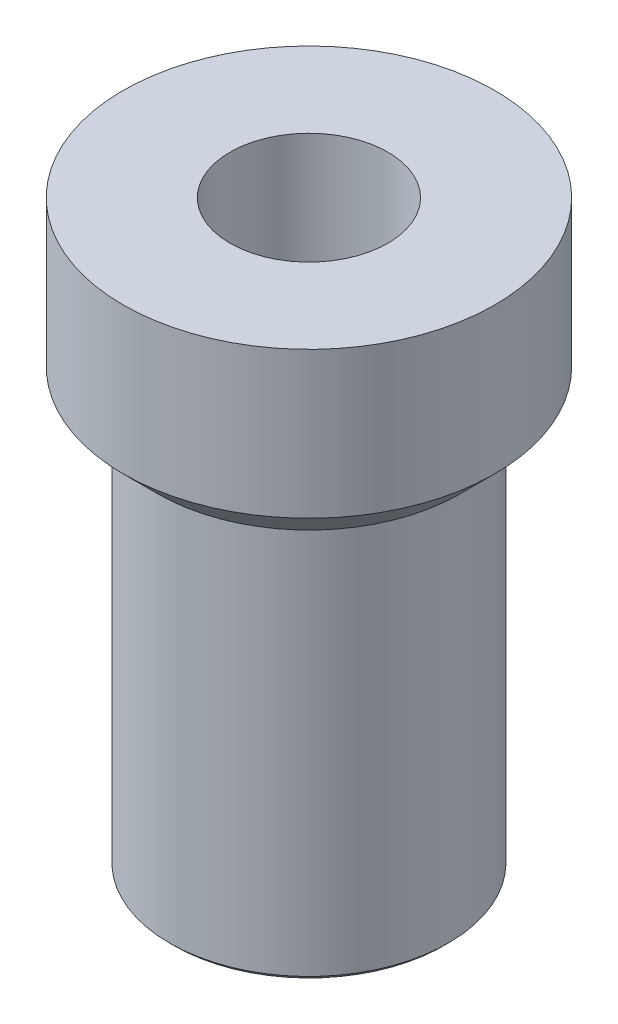
from build123d import *

# Parameters (mm, degrees)
SKETCH3_W = 3.4
SKETCH3_H = 25


with BuildPart() as part:
    # Sketch1 → Revolve1 (revolve)
    with BuildSketch(Plane.XY):
        Polygon((-6, 23.256587884), (-6, 6.256587884), (-5.8, 6.056587884), (0, 6.056587884), (0, 31.056587884), (-8, 31.056587884), (-8, 24.756587884), (-6.5, 23.256587884), align=None)
    revolve(axis=Axis((0, 31.056587884, 0), (0, -1, 0)))

    # Sketch3 → M8x1.25 Tapped Hole1 (revolve, cut)
    with BuildSketch(Plane(origin=(0, 31.056587884, 0), x_dir=(0, 0, 1), z_dir=(1, 0, 0))):
        with Locations((1.7, 12.5)):
            Rectangle(SKETCH3_W, SKETCH3_H)
    revolve(axis=Axis((0, 37.406587884, 0), (0, -1, 0)), mode=Mode.SUBTRACT)


solid = part.part
